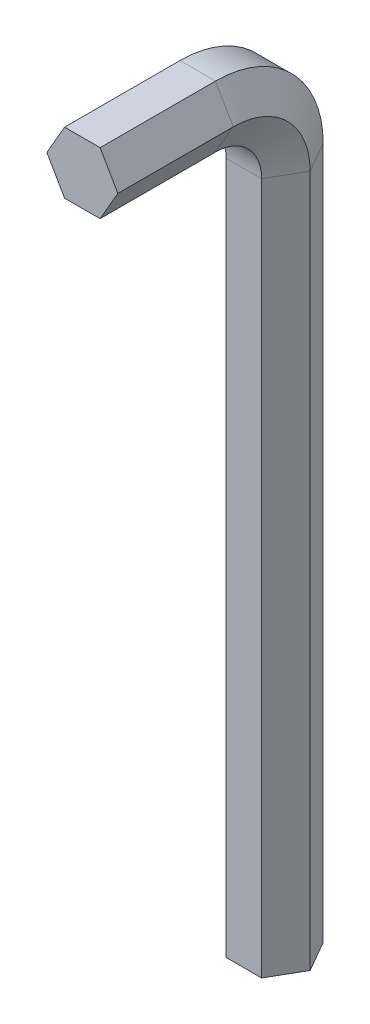
from build123d import *


with BuildPart() as part:
    # Táhnout po křivce1: sweep along a path in Skica4
    with BuildLine(Plane(origin=(0, 0, 0), x_dir=(0, 0, -1), z_dir=(1, 0, 0))) as t_hnout_po_k_ivce1_path:
        Line((0, 0), (0, 90))
        ThreePointArc((0, 90), (-2.928932188, 97.071067812), (-10, 100))
        Line((-10, 100), (-25, 100))
    # Skica2 → Táhnout po křivce1 (sweep)
    with BuildSketch(Plane(origin=(0, 0, 0), x_dir=(1, 0, 0), z_dir=(0, 1, 0))):
        Polygon((2.309401077, -4), (4.618802154, 0), (2.309401077, 4), (-2.309401077, 4), (-4.618802154, 0), (-2.309401077, -4), align=None)
    sweep(path=t_hnout_po_k_ivce1_path.line)


solid = part.part
